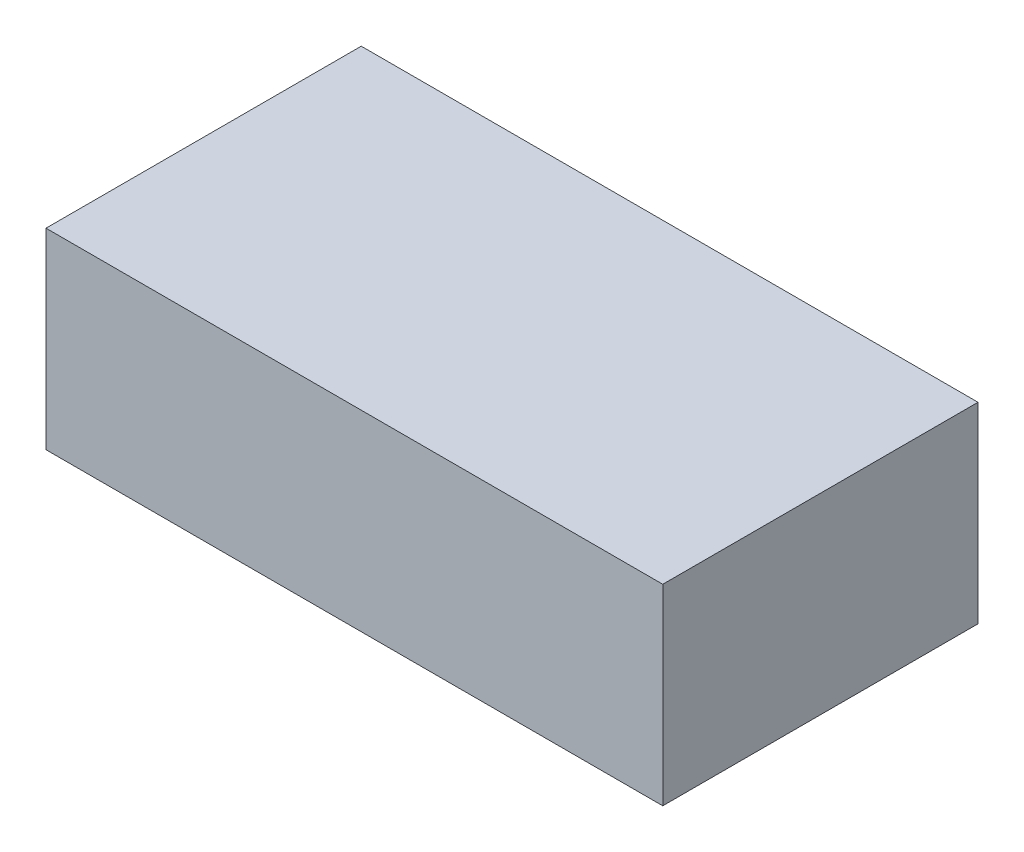
from build123d import *

# Parameters (mm, degrees)
SKETCH1_W           = 45
SKETCH1_H           = 23
BOSS_EXTRUDE1_DEPTH = 14


with BuildPart() as part:
    # Sketch1 → Boss-Extrude1 (new body)
    with BuildSketch(Plane(origin=(0, 0, 0), x_dir=(1, 0, 0), z_dir=(0, 1, 0))):
        Rectangle(SKETCH1_W, SKETCH1_H)
    extrude(amount=BOSS_EXTRUDE1_DEPTH)


solid = part.part
